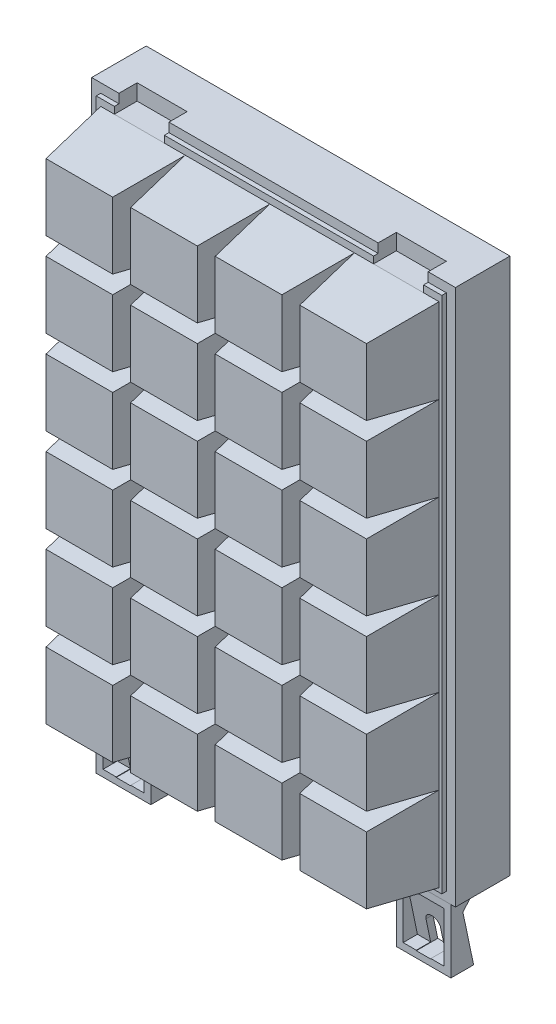
from build123d import *

# Parameters (mm, degrees)
SKETCH_1_W                  = 80
SKETCH_1_H                  = 118
EXTRUDE_1_DEPTH             = 13
SKETCH_2_W                  = 18.6
SKETCH_2_H                  = 18.6
EXTRUDE_2_DEPTH             = 14
EXTRUDE_2_TAPER             = 8
PATTERN_LINEAR_1_COUNT      = 4
PATTERN_LINEAR_1_PITCH      = 18.6
PATTERN_LINEAR_1_COUNT_DIR2 = 6
PATTERN_LINEAR_1_PITCH_DIR2 = 18.6
SKETCH_3_W                  = 11
SKETCH_3_H                  = 3.5
CUT_EXTRUDE_1_DEPTH         = 5
SKETCH_5_W                  = 80
SKETCH_5_H                  = 118
SKETCH_5_W_2                = 76
SKETCH_5_H_2                = 114
CUT_EXTRUDE_1_2_DEPTH       = 1
SKETCH_4_W                  = 12
SKETCH_4_H                  = 14
EXTRUDE_3_DEPTH             = 5
EXTRUDE_3_2_DEPTH           = 5
CUT_EXTRUDE_2_DEPTH         = 111.900856624
CUT_EXTRUDE_3_REACH         = 86.581
SKETCH_7_W                  = 9
SKETCH_7_H                  = 11


with BuildPart() as part:
    # Эскиз1 → Бобышка-Вытянуть1 (new body)
    with BuildSketch(Plane.XY):
        Rectangle(SKETCH_1_W, SKETCH_1_H)
    extrude(amount=EXTRUDE_1_DEPTH)

    # Эскиз2 → Бобышка-Вытянуть2 (add)
    with BuildSketch(Plane.XY.offset(13)):
        with Locations((-27.7, 46.2)):
            Rectangle(SKETCH_2_W, SKETCH_2_H)
    extrude_2 = extrude(amount=EXTRUDE_2_DEPTH, taper=EXTRUDE_2_TAPER)

    # Линейный массив1: Extrude 2 4 × 6
    with Locations(*[(i * PATTERN_LINEAR_1_PITCH, -j * PATTERN_LINEAR_1_PITCH_DIR2, 0) for i in range(PATTERN_LINEAR_1_COUNT) for j in range(PATTERN_LINEAR_1_COUNT_DIR2) if (i, j) != (0, 0)]):
        add(extrude_2)

    # Эскиз3 → Cut-Extrude 1 (cut)
    with BuildSketch(Plane.XY.offset(13)):
        with Locations((-28.5, 57.25)):
            Rectangle(SKETCH_3_W, SKETCH_3_H)
        with Locations((28.5, 57.25)):
            Rectangle(SKETCH_3_W, SKETCH_3_H)
    extrude(amount=-CUT_EXTRUDE_1_DEPTH, mode=Mode.SUBTRACT)

    # Эскиз5 → Cut-Extrude 1 2 (cut)
    with BuildSketch(Plane.XY.offset(13)):
        Rectangle(SKETCH_5_W, SKETCH_5_H)
        Rectangle(SKETCH_5_W_2, SKETCH_5_H_2, mode=Mode.SUBTRACT)
    extrude(amount=-CUT_EXTRUDE_1_2_DEPTH, mode=Mode.SUBTRACT)


with BuildPart() as body_2:
    # Эскиз4 → Бобышка-Вытянуть3 (new body)
    with BuildSketch(Plane.XY.offset(12)):
        with Locations((-33, -66)):
            Rectangle(SKETCH_4_W, SKETCH_4_H)
        with BuildLine():
            Line((-34.6, -66.6), (-34.6, -71.6))
            Line((-34.6, -71.6), (-31.4, -71.6))
            Line((-31.4, -71.6), (-31.4, -66.6))
            ThreePointArc((-31.4, -66.6), (-33, -65), (-34.6, -66.6))
        make_face(mode=Mode.SUBTRACT)
    extrude(amount=-EXTRUDE_3_DEPTH)


with BuildPart() as body_3:
    # Эскиз4 → Extrude 3 2 (new body)
    with BuildSketch(Plane.XY.offset(12)):
        with Locations((33, -66)):
            Rectangle(SKETCH_4_W, SKETCH_4_H)
        with BuildLine():
            Line((31.4, -66.6), (31.4, -71.6))
            Line((31.4, -71.6), (34.6, -71.6))
            Line((34.6, -71.6), (34.6, -66.6))
            ThreePointArc((34.6, -66.6), (33, -65), (31.4, -66.6))
        make_face(mode=Mode.SUBTRACT)
    extrude(amount=-EXTRUDE_3_2_DEPTH)


with BuildPart() as cut_extrude_2_tool:
    # Эскиз6 → Вырез-Вытянуть2 (new, through all)
    with BuildSketch(Plane.ZY.offset(39)):
        Polygon((7, -73), (9.350197069, -61.800584239), (7, -59), align=None)
    extrude(amount=-CUT_EXTRUDE_2_DEPTH)


with BuildPart() as body_2_1:
    add(body_2.part)

    # Вырез-Вытянуть2: cut by cut_extrude_2_tool
    add(cut_extrude_2_tool.part, mode=Mode.SUBTRACT)


with BuildPart() as body_3_1:
    add(body_3.part)

    # Вырез-Вытянуть2: cut by cut_extrude_2_tool
    add(cut_extrude_2_tool.part, mode=Mode.SUBTRACT)


with BuildPart() as cut_extrude_3_tool:
    # Вырез-Вытянуть3: up to this plane
    cut_extrude_3_end = Plane(origin=(40, -73.308064904, 8.468024528), z_dir=(0, -0.20537660273747238, 0.9786830186776587))
    # Эскиз7 → Вырез-Вытянуть3 (new, up to the surface)
    with BuildSketch(Plane.XY.offset(12), mode=Mode.PRIVATE) as cut_extrude_3_sk1:
        with Locations((-33, -66)):
            Rectangle(SKETCH_7_W, SKETCH_7_H)
    cut_extrude_3_tool1 = split(extrude(cut_extrude_3_sk1.sketch, amount=-CUT_EXTRUDE_3_REACH, mode=Mode.PRIVATE), bisect_by=cut_extrude_3_end, keep=Keep.BOTH, mode=Mode.PRIVATE)
    add(cut_extrude_3_tool1.solids().sort_by_distance((-33, -66, 12))[0])
    # Эскиз7 → Вырез-Вытянуть3 (new, up to the surface)
    with BuildSketch(Plane.XY.offset(12), mode=Mode.PRIVATE) as cut_extrude_3_sk2:
        with Locations((33, -66)):
            Rectangle(SKETCH_7_W, SKETCH_7_H)
    cut_extrude_3_tool2 = split(extrude(cut_extrude_3_sk2.sketch, amount=-CUT_EXTRUDE_3_REACH, mode=Mode.PRIVATE), bisect_by=cut_extrude_3_end, keep=Keep.BOTH, mode=Mode.PRIVATE)
    add(cut_extrude_3_tool2.solids().sort_by_distance((33, -66, 12))[0])


with BuildPart() as body_2_2:
    add(body_2_1.part)

    # Вырез-Вытянуть3: cut by cut_extrude_3_tool
    add(cut_extrude_3_tool.part, mode=Mode.SUBTRACT)


with BuildPart() as body_3_2:
    add(body_3_1.part)

    # Вырез-Вытянуть3: cut by cut_extrude_3_tool
    add(cut_extrude_3_tool.part, mode=Mode.SUBTRACT)


solid = Compound([part.part, body_2_2.part, body_3_2.part])
